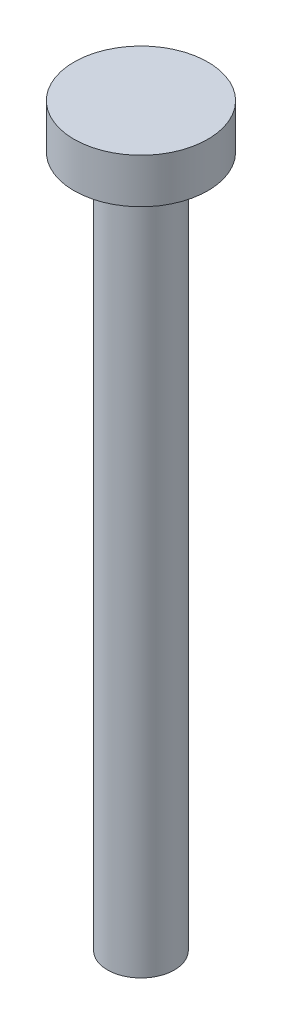
from build123d import *

# Parameters (mm, degrees)
SKETCH1_R           = 1.5
BOSS_EXTRUDE1_DEPTH = 31
SKETCH2_R           = 3
BOSS_EXTRUDE2_DEPTH = 2
FILLET1_R           = 1


with BuildPart() as part:
    # Sketch1 → Boss-Extrude1 (new body)
    with BuildSketch(Plane(origin=(0, 0, 0), x_dir=(1, 0, 0), z_dir=(0, 1, 0))):
        Circle(SKETCH1_R)
    extrude(amount=BOSS_EXTRUDE1_DEPTH)

    # Sketch2 → Boss-Extrude2 (add)
    with BuildSketch(Plane(origin=(0, 31, 0), x_dir=(1, 0, 0), z_dir=(0, 1, 0))):
        Circle(SKETCH2_R)
    extrude(amount=BOSS_EXTRUDE2_DEPTH)

    # Fillet1
    fillet1_edges = [part.edges().sort_by_distance(p)[0] for p in [
        (-1.5, 31, 0),
    ]]
    fillet(fillet1_edges, radius=FILLET1_R)


solid = part.part
